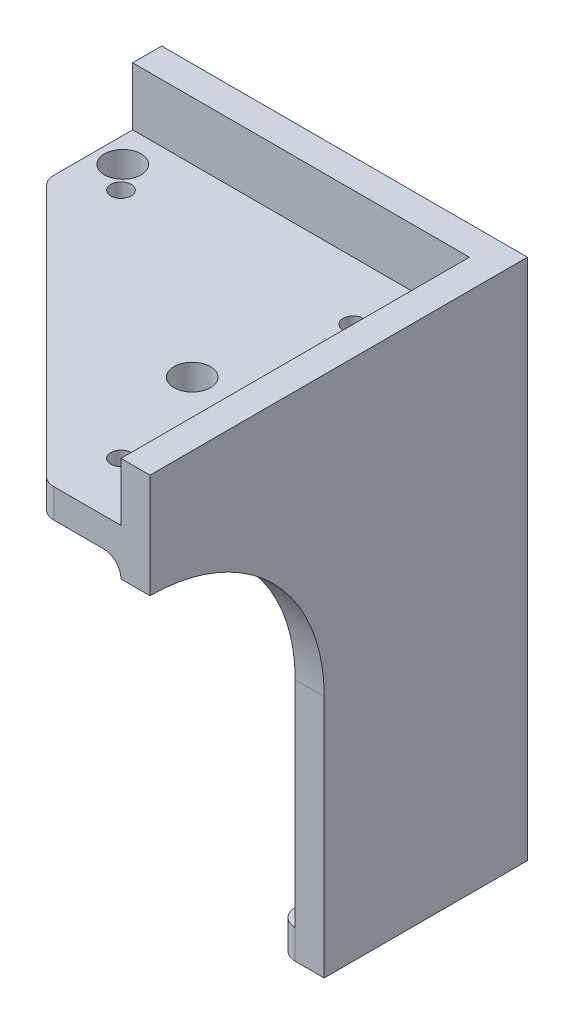
from build123d import *

# Parameters (mm, degrees)
SALIENTE_EXTRUIR1_DEPTH = 5
CROQUIS2_W              = 5
CROQUIS2_H              = 90
SALIENTE_EXTRUIR2_DEPTH = 60
CORTAR_EXTRUIR1_DEPTH   = 5
SALIENTE_EXTRUIR3_DEPTH = 5
REDONDEO1_R             = 3
CROQUIS5_W              = 58
CROQUIS5_H              = 5
SALIENTE_EXTRUIR4_DEPTH = 60
CORTAR_EXTRUIR2_DEPTH   = 5
REDONDEO2_R             = 3
REDONDEO3_R             = 3
CROQUIS7_R              = 1.75
CROQUIS7_R_2            = 3.15
CORTAR_EXTRUIR3_DEPTH   = 5


with BuildPart() as part:
    # Croquis1 → Saliente-Extruir1 (new body)
    with BuildSketch(Plane.XY):
        with BuildLine():
            Line((-63, 0), (0, 0))
            Line((0, 0), (0, -90))
            Line((0, -90), (-33, -90))
            Line((-33, -90), (-33, -48))
            ThreePointArc((-33, -48), (-41.786797, -26.786797), (-63, -18))
            Line((-63, -18), (-63, 0))
        make_face()
    extrude(amount=SALIENTE_EXTRUIR1_DEPTH)

    # Croquis2 → Saliente-Extruir2 (add)
    with BuildSketch(Plane.XY.offset(5)):
        with Locations((-2.5, -45)):
            Rectangle(CROQUIS2_W, CROQUIS2_H)
    extrude(amount=SALIENTE_EXTRUIR2_DEPTH)

    # Croquis3 → Cortar-Extruir1 (cut)
    with BuildSketch(Plane(origin=(0, 0, 0), x_dir=(0, 0, -1), z_dir=(1, 0, 0))):
        with BuildLine():
            Line((-65, -90), (-35, -90))
            Line((-35, -90), (-35, -48))
            ThreePointArc((-35, -48), (-43.786797, -26.786797), (-65, -18))
            Line((-65, -18), (-65, -90))
        make_face()
    extrude(amount=-CORTAR_EXTRUIR1_DEPTH, mode=Mode.SUBTRACT)

    # Croquis4 → Saliente-Extruir3 (add)
    with BuildSketch(Plane.XZ.offset(90)):
        Polygon((-33, 8), (-8, 8), (-8, 35), (-5, 35), (-5, 5), (-33, 5), align=None)
    extrude(amount=-SALIENTE_EXTRUIR3_DEPTH)

    # Redondeo1
    redondeo1_edges = [part.edges().sort_by_distance(p)[0] for p in [
        (-33, -87.5, 8),
        (-8, -87.5, 35),
    ]]
    fillet(redondeo1_edges, radius=REDONDEO1_R)

    # Croquis5 → Saliente-Extruir4 (add)
    with BuildSketch(Plane.XY.offset(5)):
        with Locations((-34, -12.5)):
            Rectangle(CROQUIS5_W, CROQUIS5_H)
    extrude(amount=SALIENTE_EXTRUIR4_DEPTH)

    # Croquis6 → Cortar-Extruir2 (cut)
    with BuildSketch(Plane(origin=(0, -10, 0), x_dir=(1, 0, 0), z_dir=(0, 1, 0))):
        Polygon((-63, -19.817641), (-17.817641, -65), (-63, -65), align=None)
    extrude(amount=-CORTAR_EXTRUIR2_DEPTH, mode=Mode.SUBTRACT)

    # Redondeo2
    redondeo2_edges = [part.edges().sort_by_distance(p)[0] for p in [
        (-63, -12.5, 19.817641),
        (-17.817641, -12.5, 65),
    ]]
    fillet(redondeo2_edges, radius=REDONDEO2_R)

    # Redondeo3
    redondeo3_edges = [part.edges().sort_by_distance(p)[0] for p in [
        (-34, -15, 5),
        (-5, -15, 35),
        (-5, -50, 5),
    ]]
    fillet(redondeo3_edges, radius=REDONDEO3_R)

    # Croquis7 → Cortar-Extruir3 (cut)
    with BuildSketch(Plane(origin=(0, -10, 0), x_dir=(1, 0, 0), z_dir=(0, 1, 0))):
        with Locations((-15, -55)):
            Circle(CROQUIS7_R)
        with Locations((-15, -15)):
            Circle(CROQUIS7_R)
        with Locations((-55, -15)):
            Circle(CROQUIS7_R)
        with Locations((-58.699976, -11)):
            Circle(CROQUIS7_R_2)
        with Locations((-20.975, -36.755655)):
            Circle(CROQUIS7_R_2)
    extrude(amount=-CORTAR_EXTRUIR3_DEPTH, mode=Mode.SUBTRACT)


solid = part.part
